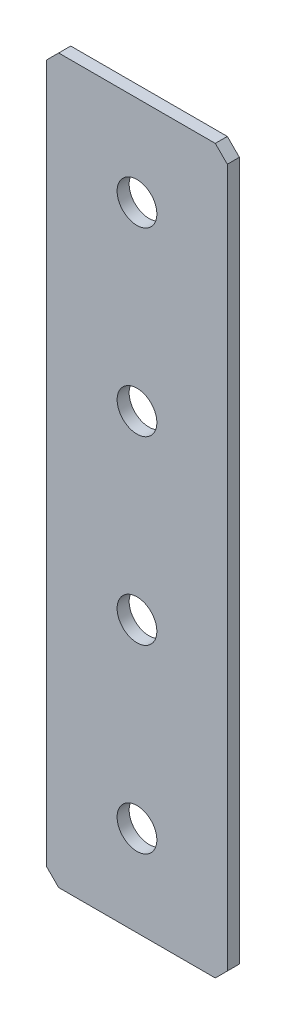
from build123d import *

# Parameters (mm, degrees)
SKETCH_1_W        = 30
SKETCH_1_H        = 120
EXTRUDE_1_DEPTH   = 2
CHAMFER_1_SIZE    = 2
HOLE_WIZARD_M61_D = 6.6


with BuildPart() as part:
    # Эскиз1 → Бобышка-Вытянуть1 (new body)
    with BuildSketch(Plane.XY):
        Rectangle(SKETCH_1_W, SKETCH_1_H)
    extrude(amount=EXTRUDE_1_DEPTH)

    # Фаска1
    chamfer_1_edges = [part.edges().sort_by_distance(p)[0] for p in [
        (15, -60, 1),
        (-15, -60, 1),
        (-15, 60, 1),
        (15, 60, 1),
    ]]
    chamfer(chamfer_1_edges, length=CHAMFER_1_SIZE)

    # Отверстие с зазором M61 (through all)
    with Locations(Plane.XY.offset(2)):
        with Locations((0, -45), (0, 45), (0, 15), (0, -15)):
            Hole(HOLE_WIZARD_M61_D / 2)


solid = part.part
